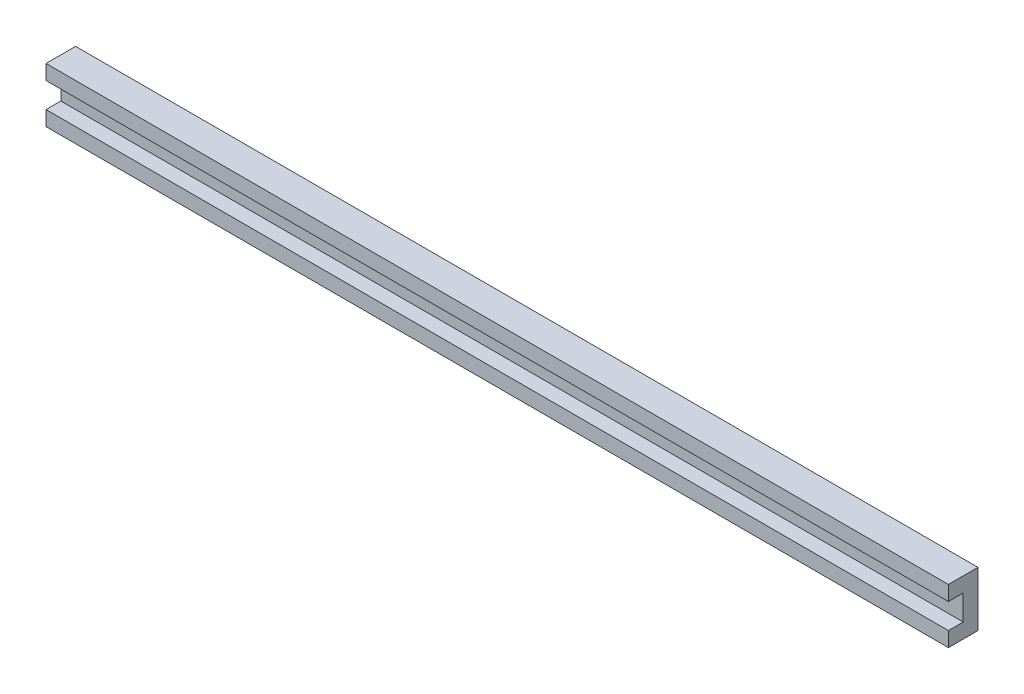
from build123d import *

# Parameters (mm, degrees)
BOSS_EXTRUDE1_DEPTH = 1549.4


with BuildPart() as part:
    # Sketch1 → Boss-Extrude1 (new body)
    with BuildSketch(Plane(origin=(0, 0, 0), x_dir=(0, 0, -1), z_dir=(1, 0, 0))):
        Polygon((0, 0), (50.8, 0), (50.8, 93.98), (0, 93.98), (0, 68.58), (25.4, 68.58), (25.4, 25.4), (0, 25.4), align=None)
    extrude(amount=BOSS_EXTRUDE1_DEPTH)


solid = part.part
